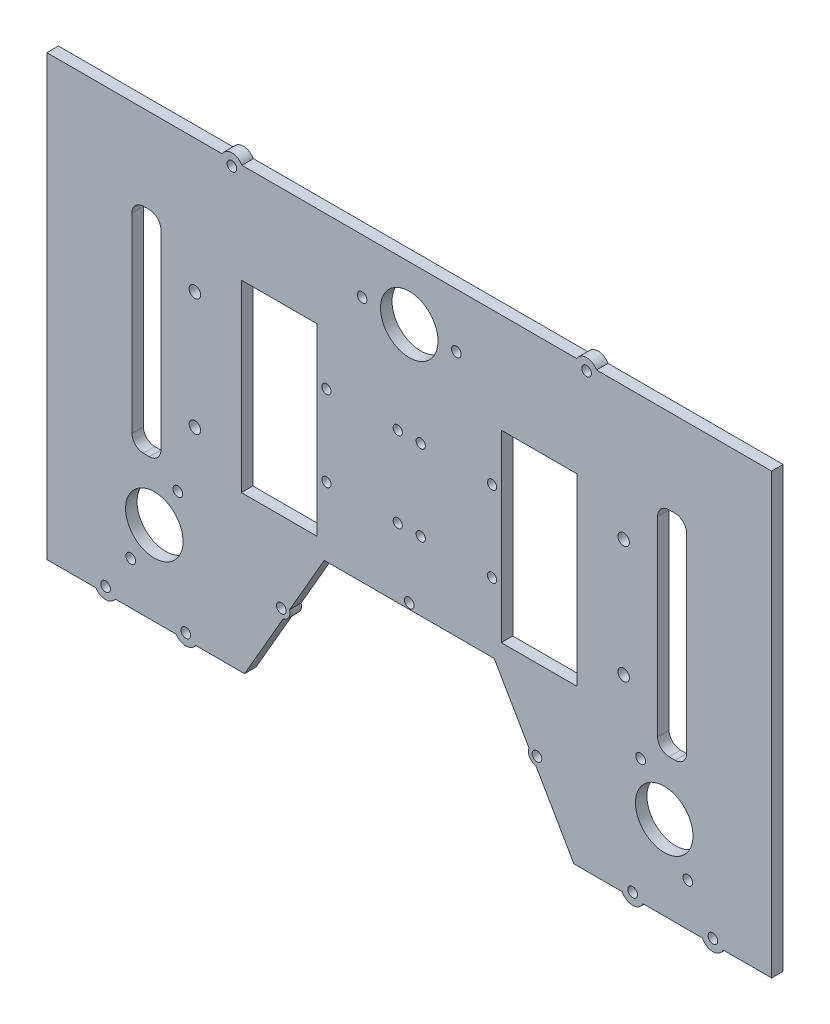
from build123d import *

# Parameters (mm, degrees)
SKETCH1_R           = 2.1
SKETCH1_R_2         = 12.5
SKETCH1_R_3         = 2
SKETCH1_R_4         = 2.5
SKETCH1_R_5         = 2.100093489
SKETCH1_R_6         = 2.100208614
SKETCH1_W           = 33
SKETCH1_H           = 80
BOSS_EXTRUDE1_DEPTH = 5


with BuildPart() as part:
    # Sketch1 → Boss-Extrude1 (new body)
    with BuildSketch(Plane.XY):
        with BuildLine():
            Line((101.645117601, -93.770346549), (127.497608455, -93.770346549))
            ThreePointArc((127.497608455, -93.770346549), (132.017726056, -96.632932955), (136.537843658, -93.770346549))
            Line((136.537843658, -93.770346549), (157.551292677, -93.770346549))
            Line((157.551292677, -93.770346549), (157.551292677, 97.083097938))
            Line((157.551292677, 97.083097938), (81.43113923, 97.083097938))
            ThreePointArc((81.43113923, 97.083097938), (77.101012211, 99.583097938), (72.770885192, 97.083097938))
            Line((72.770885192, 97.083097938), (36.650918722, 97.083097938))
            Line((36.650918722, 97.083097938), (-36.650918722, 97.083097938))
            Line((-36.650918722, 97.083097938), (-72.770791704, 97.083097938))
            ThreePointArc((-72.770791704, 97.083097938), (-77.100918722, 99.583097938), (-81.431045741, 97.083097938))
            Line((-81.431045741, 97.083097938), (-157.551292677, 97.083097938))
            Line((-157.551292677, 97.083097938), (-157.551292677, -93.770346549))
            Line((-157.551292677, -93.770346549), (-136.247071986, -93.770346549))
            ThreePointArc((-136.247071986, -93.770346549), (-132.0168916, -96.104718311), (-127.786711214, -93.770346549))
            Line((-127.786711214, -93.770346549), (-101.356014842, -93.770346549))
            ThreePointArc((-101.356014842, -93.770346549), (-97.125834456, -96.104718311), (-92.89565407, -93.770346549))
            Line((-92.89565407, -93.770346549), (-71.59143338, -93.770346549))
            Line((-71.59143338, -93.770346549), (-54.846081626, -64.766546521))
            ThreePointArc((-54.846081626, -64.766546521), (-52.366007385, -62.970931929), (-52.050996654, -59.925317338))
            Line((-52.050996654, -59.925317338), (-36.950417228, -33.770346549))
            Line((-36.950417228, -33.770346549), (36.950417228, -33.770346549))
            Line((36.950417228, -33.770346549), (52.039816857, -59.905953361))
            ThreePointArc((52.039816857, -59.905953361), (52.273889994, -63.173966334), (54.987035679, -65.010686103))
            Line((54.987035679, -65.010686103), (71.59143338, -93.770346549))
            Line((71.59143338, -93.770346549), (92.604882399, -93.770346549))
            ThreePointArc((92.604882399, -93.770346549), (97.125, -96.632932955), (101.645117601, -93.770346549))
        make_face()
        with Locations((20.5, 73.517875823)):
            Circle(SKETCH1_R, mode=Mode.SUBTRACT)
        with Locations((-20.5, 73.517875823)):
            Circle(SKETCH1_R, mode=Mode.SUBTRACT)
        with Locations((0, 73.517875823)):
            Circle(SKETCH1_R_2, mode=Mode.SUBTRACT)
        with Locations((36, 31.229653451)):
            Circle(SKETCH1_R_3, mode=Mode.SUBTRACT)
        with Locations((-5, -3.770346549)):
            Circle(SKETCH1_R_3, mode=Mode.SUBTRACT)
        with Locations((5, -3.770346549)):
            Circle(SKETCH1_R_3, mode=Mode.SUBTRACT)
        with Locations((36, -3.770346549)):
            Circle(SKETCH1_R_3, mode=Mode.SUBTRACT)
        with Locations((-36, 31.229653451)):
            Circle(SKETCH1_R_3, mode=Mode.SUBTRACT)
        with Locations((-5, 31.229653451)):
            Circle(SKETCH1_R_3, mode=Mode.SUBTRACT)
        with Locations((5, 31.229653451)):
            Circle(SKETCH1_R_3, mode=Mode.SUBTRACT)
        with Locations((-36, -3.770346549)):
            Circle(SKETCH1_R_3, mode=Mode.SUBTRACT)
        with Locations((93.2, 39.229653451)):
            Circle(SKETCH1_R_4, mode=Mode.SUBTRACT)
        with Locations((-93.2, 39.229653451)):
            Circle(SKETCH1_R_4, mode=Mode.SUBTRACT)
        with Locations((-93.2, -11.770346549)):
            Circle(SKETCH1_R_4, mode=Mode.SUBTRACT)
        with Locations((93.2, -11.770346549)):
            Circle(SKETCH1_R_4, mode=Mode.SUBTRACT)
        with Locations((-77.100918722, 94.583097938)):
            Circle(SKETCH1_R, mode=Mode.SUBTRACT)
        with Locations((-97.125834456, -91.104718311)):
            Circle(SKETCH1_R, mode=Mode.SUBTRACT)
        with Locations((-55.613602649, -61.095931929)):
            Circle(SKETCH1_R, mode=Mode.SUBTRACT)
        with Locations((77.101012211, 94.583097938)):
            Circle(SKETCH1_R_5, mode=Mode.SUBTRACT)
        with Locations((97.125, -91.632932955)):
            Circle(SKETCH1_R, mode=Mode.SUBTRACT)
        with Locations((55.521485258, -61.298966334)):
            Circle(SKETCH1_R, mode=Mode.SUBTRACT)
        with Locations((-0.000208614, -31.270346549)):
            Circle(SKETCH1_R_6, mode=Mode.SUBTRACT)
        with Locations((-100.592116007, -39.629860895)):
            Circle(SKETCH1_R, mode=Mode.SUBTRACT)
        with Locations((-121.092116007, -75.13690245)):
            Circle(SKETCH1_R, mode=Mode.SUBTRACT)
        with Locations((-110.842116007, -57.383381672)):
            Circle(SKETCH1_R_2, mode=Mode.SUBTRACT)
        with Locations((-132.0168916, -91.104718311)):
            Circle(SKETCH1_R, mode=Mode.SUBTRACT)
        with Locations((132.017726056, -91.632932955)):
            Circle(SKETCH1_R, mode=Mode.SUBTRACT)
        with Locations((121.092116007, -75.13690245)):
            Circle(SKETCH1_R, mode=Mode.SUBTRACT)
        with Locations((100.592116007, -39.629860895)):
            Circle(SKETCH1_R, mode=Mode.SUBTRACT)
        with Locations((110.842116007, -57.383381672)):
            Circle(SKETCH1_R_2, mode=Mode.SUBTRACT)
        with Locations((-56.5, 13.729653451)):
            Rectangle(SKETCH1_W, SKETCH1_H, mode=Mode.SUBTRACT)
        with Locations((56.5, 13.729653451)):
            Rectangle(SKETCH1_W, SKETCH1_H, mode=Mode.SUBTRACT)
        with BuildLine():
            Line((-112.97, 60.222473641), (-115.57, 60.222473641))
            ThreePointArc((-115.57, 60.222473641), (-119.105533906, 58.758007547), (-120.57, 55.222473641))
            Line((-120.57, 55.222473641), (-120.57, -27.763166739))
            ThreePointArc((-120.57, -27.763166739), (-119.105533906, -31.298700645), (-115.57, -32.763166739))
            Line((-115.57, -32.763166739), (-112.97, -32.763166739))
            ThreePointArc((-112.97, -32.763166739), (-109.434466094, -31.298700645), (-107.97, -27.763166739))
            Line((-107.97, -27.763166739), (-107.97, 55.222473641))
            ThreePointArc((-107.97, 55.222473641), (-109.434466094, 58.758007547), (-112.97, 60.222473641))
        make_face(mode=Mode.SUBTRACT)
        with BuildLine():
            Line((112.97, -32.763166739), (115.57, -32.763166739))
            ThreePointArc((115.57, -32.763166739), (119.105533906, -31.298700645), (120.57, -27.763166739))
            Line((120.57, -27.763166739), (120.57, 55.222473641))
            ThreePointArc((120.57, 55.222473641), (119.105533906, 58.758007547), (115.57, 60.222473641))
            Line((115.57, 60.222473641), (112.97, 60.222473641))
            ThreePointArc((112.97, 60.222473641), (109.434466094, 58.758007547), (107.97, 55.222473641))
            Line((107.97, 55.222473641), (107.97, -27.763166739))
            ThreePointArc((107.97, -27.763166739), (109.434466094, -31.298700645), (112.97, -32.763166739))
        make_face(mode=Mode.SUBTRACT)
    extrude(amount=BOSS_EXTRUDE1_DEPTH)


solid = part.part
